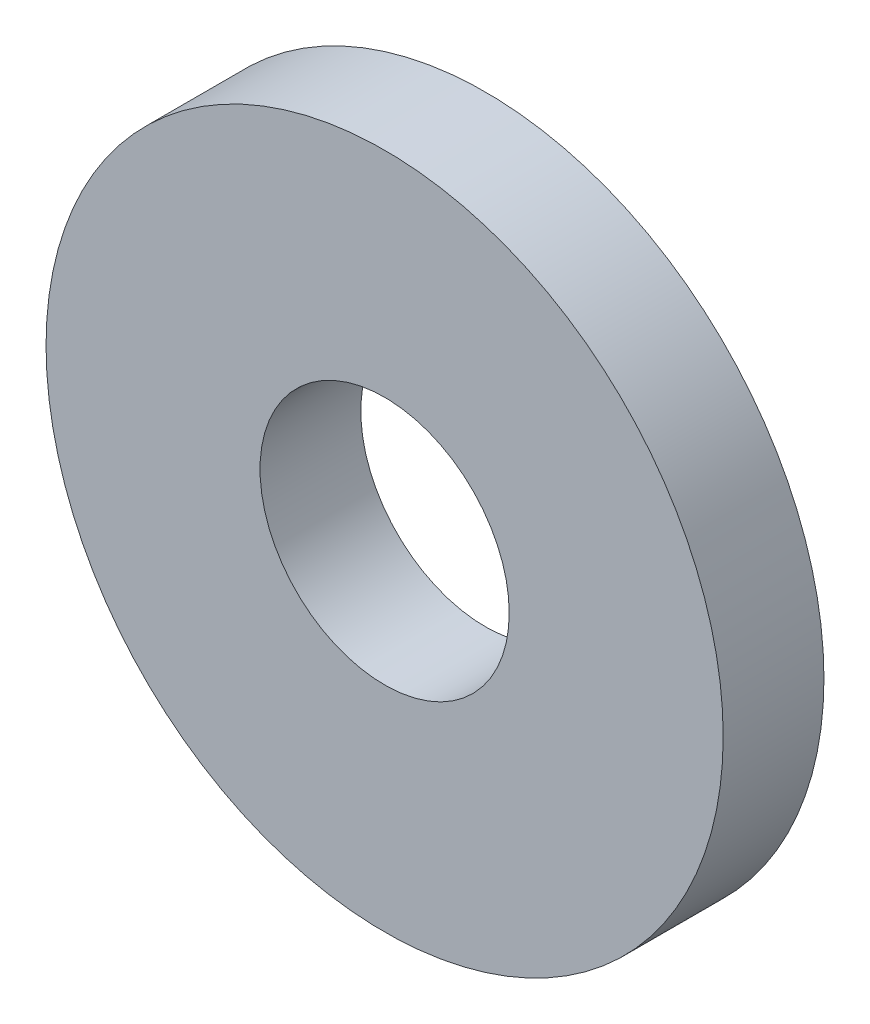
from build123d import *

# Parameters (mm, degrees)
SKETCH1_R      = 7.9375
SKETCH1_R_2    = 2.921
EXTRUDE1_DEPTH = 2.3622


with BuildPart() as part:
    # Sketch1 → Extrude1 (new body)
    with BuildSketch(Plane.XY):
        Circle(SKETCH1_R)
        Circle(SKETCH1_R_2, mode=Mode.SUBTRACT)
    extrude(amount=-EXTRUDE1_DEPTH)


solid = part.part
